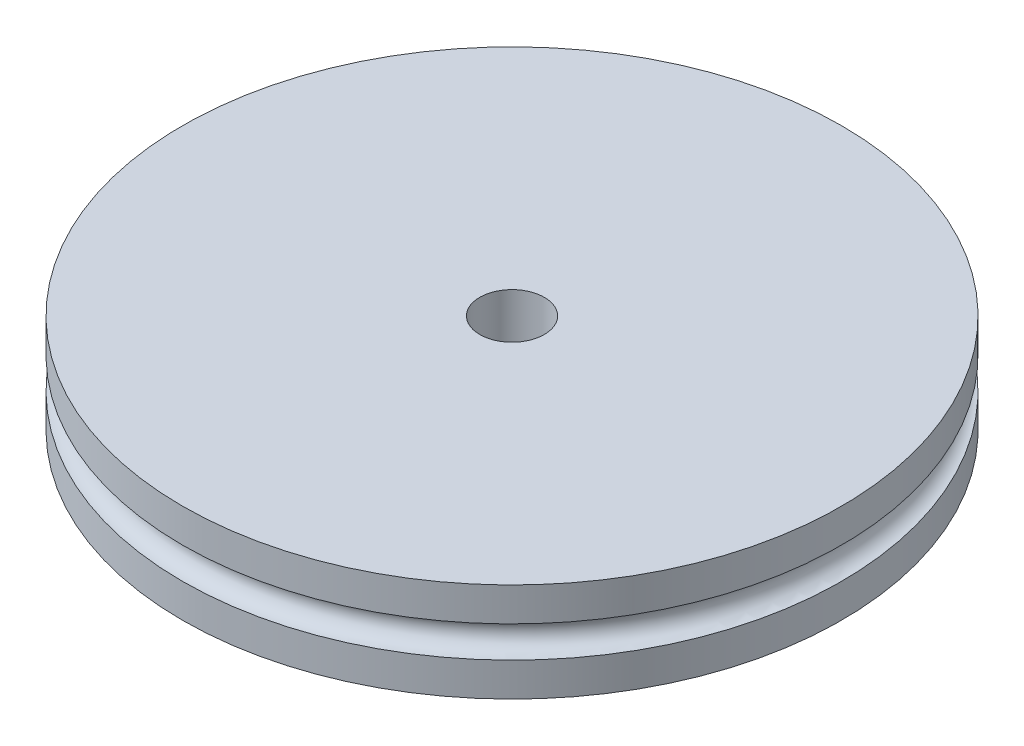
from build123d import *

# Parameters (mm, degrees)
SKETCH1_R                = 33.3375
BOSS_EXTRUDE1_DEPTH      = 10
SKETCH2_R                = 1.5875
F_5_16_18_TAPPED_HOLE1_D = 6.5278


with BuildPart() as part:
    # Sketch1 → Boss-Extrude1 (new body)
    with BuildSketch(Plane(origin=(0, 0, 0), x_dir=(1, 0, 0), z_dir=(0, 1, 0))):
        Circle(SKETCH1_R)
    extrude(amount=BOSS_EXTRUDE1_DEPTH)

    # Sketch2 → Cut-Revolve1 (revolve, cut)
    with BuildSketch(Plane.XY):
        with Locations((33.3375, 5)):
            Circle(SKETCH2_R)
    revolve(axis=Axis((0, 10, 0), (0, -1, 0)), mode=Mode.SUBTRACT)

    # 5/16-18 Tapped Hole1 (through all)
    with Locations(Plane(origin=(0, 10, 0), x_dir=(1, 0, 0), z_dir=(0, 1, 0))):
        with Locations((0, 0)):
            Hole(F_5_16_18_TAPPED_HOLE1_D / 2)


solid = part.part
